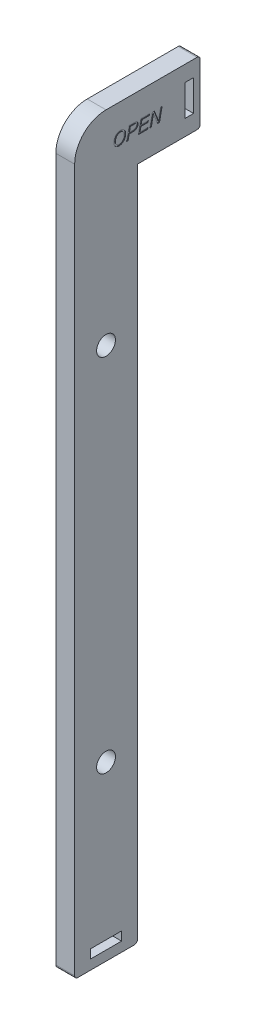
from build123d import *

# Parameters (mm, degrees)
SKETCH_1_R          = 3
SKETCH_1_W          = 2.81
SKETCH_1_H          = 9.9
SKETCH_1_W_2        = 9.9
SKETCH_1_H_2        = 2.81
EXTRUDE_1_DEPTH     = 6
FILLET_1_R          = 1
FILLET_2_R          = 10
CUT_EXTRUDE_1_DEPTH = 0.2


with BuildPart() as part:
    # Эскиз1 → Бобышка-Вытянуть1 (new body)
    with BuildSketch(Plane(origin=(0, 0, 0), x_dir=(0, 0, -1), z_dir=(1, 0, 0))):
        Polygon((0, 0), (0, 215), (20, 215), (20, 235), (-20, 235), (-20, 0), align=None)
        with Locations((-10, 170)):
            Circle(SKETCH_1_R, mode=Mode.SUBTRACT)
        with Locations((-10, 55)):
            Circle(SKETCH_1_R, mode=Mode.SUBTRACT)
        with Locations((16.5, 225)):
            Rectangle(SKETCH_1_W, SKETCH_1_H, mode=Mode.SUBTRACT)
        with Locations((-10, 4.5)):
            Rectangle(SKETCH_1_W_2, SKETCH_1_H_2, mode=Mode.SUBTRACT)
    extrude(amount=EXTRUDE_1_DEPTH)

    # Скругление1
    fillet_1_edges = [part.edges().sort_by_distance(p)[0] for p in [
        (3, 235, -20),
        (3, 215, -20),
        (3, 0, 0),
        (3, 0, 20),
    ]]
    fillet(fillet_1_edges, radius=FILLET_1_R)

    # Скругление2
    fillet_2_edges = [part.edges().sort_by_distance(p)[0] for p in [
        (3, 235, 20),
    ]]
    fillet(fillet_2_edges, radius=FILLET_2_R)

    # Эскиз2 → Вырез-Вытянуть1 (cut)
    with BuildSketch(Plane(origin=(6, 0, 0), x_dir=(0, 0, -1), z_dir=(1, 0, 0))):
        with BuildLine():
            add(Edge.make_bspline(
                [(-7.487179487, 224.677884615), (-7.485326408, 224.764228952), (-7.481701855, 224.933115174), (-7.453533272, 225.180402313), (-7.405449993, 225.414943216), (-7.338993125, 225.637130201), (-7.253996452, 225.846742618), (-7.149347867, 226.04336703), (-7.025073815, 226.227176251), (-6.883090978, 226.396637417), (-6.727847675, 226.549715899), (-6.562769143, 226.683595069), (-6.389954814, 226.797562377), (-6.208419068, 226.890113867), (-6.019193495, 226.962918256), (-5.821389971, 227.014196779), (-5.615570018, 227.045256359), (-5.475535074, 227.049256915), (-5.404647436, 227.051282051)],
                knots=[0, 0, 0, 0, 0.000258993, 0.00050658, 0.000745442, 0.00097638, 0.001201362, 0.001422893, 0.001643355, 0.001865778, 0.002085056, 0.002296419, 0.002502438, 0.00270491, 0.002906548, 0.00310945, 0.003316826, 0.003529421, 0.003529421, 0.003529421, 0.003529421], degree=3))
            add(Edge.make_bspline(
                [(-5.404647436, 227.051282051), (-5.344733658, 227.050103816), (-5.227104213, 227.047790574), (-5.055229995, 227.023499838), (-4.89162471, 226.986403057), (-4.73679064, 226.933371306), (-4.591031255, 226.864500305), (-4.452768198, 226.782053634), (-4.324506847, 226.68224076), (-4.204276819, 226.570025181), (-4.096454743, 226.443984872), (-4.001008783, 226.307571127), (-3.922030267, 226.159685443), (-3.855291131, 226.002622461), (-3.805464676, 225.834464234), (-3.769493026, 225.656434414), (-3.747480766, 225.468233417), (-3.744907385, 225.339269964), (-3.743589744, 225.273237179)],
                knots=[0, 0, 0, 0, 0.000179632, 0.000352674, 0.000519637, 0.000682319, 0.000842547, 0.001002503, 0.001164213, 0.00132917, 0.001495084, 0.001660901, 0.001827617, 0.00199712, 0.002172031, 0.002352748, 0.002541492, 0.00273954, 0.00273954, 0.00273954, 0.00273954], degree=3))
            add(Edge.make_bspline(
                [(-3.743589744, 225.273237179), (-3.744501677, 225.225412884), (-3.746312353, 225.130456103), (-3.756460739, 224.989408881), (-3.775282342, 224.850919386), (-3.800697074, 224.714995056), (-3.833519677, 224.581730978), (-3.874064544, 224.451338896), (-3.920666742, 224.323154229), (-3.958077126, 224.240167875), (-3.976762821, 224.198717949)],
                knots=[0, 0, 0, 0, 0.000143485, 0.000284895, 0.000423943, 0.000562553, 0.000699563, 0.000835412, 0.000972056, 0.001108416, 0.001108416, 0.001108416, 0.001108416], degree=3))
            add(Edge.make_bspline(
                [(-3.976762821, 224.198717949), (-4.006738473, 224.138603197), (-4.065863347, 224.02003106), (-4.171141209, 223.85350135), (-4.287224418, 223.699163445), (-4.414481077, 223.558810008), (-4.549180195, 223.431992287), (-4.689198476, 223.319864604), (-4.833954781, 223.221912027), (-4.935871468, 223.169435313), (-4.986378205, 223.143429487)],
                knots=[0, 0, 0, 0, 0.000201415, 0.000397278, 0.000590067, 0.00078012, 0.000964915, 0.00114449, 0.001317834, 0.001488132, 0.001488132, 0.001488132, 0.001488132], degree=3))
            add(Edge.make_bspline(
                [(-4.986378205, 223.143429487), (-5.019831399, 223.127732662), (-5.086665116, 223.096373109), (-5.190137006, 223.057961737), (-5.294434062, 223.023645555), (-5.400555284, 222.996744895), (-5.507976716, 222.974777914), (-5.617167929, 222.959652913), (-5.727948653, 222.950748644), (-5.802334429, 222.949397466), (-5.83974359, 222.948717949)],
                knots=[0, 0, 0, 0, 0.000110812, 0.000221383, 0.000330851, 0.000440073, 0.000549602, 0.000659635, 0.000770563, 0.000882788, 0.000882788, 0.000882788, 0.000882788], degree=3))
            add(Edge.make_bspline(
                [(-5.83974359, 222.948717949), (-5.878771843, 222.949165688), (-5.955928815, 222.950050847), (-6.070123979, 222.962191112), (-6.181796987, 222.979412045), (-6.290829023, 223.00416944), (-6.396862181, 223.03671596), (-6.500890974, 223.074733064), (-6.601557508, 223.12192274), (-6.700235834, 223.173931071), (-6.793301874, 223.234421204), (-6.882279427, 223.299167712), (-6.964468813, 223.370549532), (-7.041309903, 223.447391309), (-7.112443074, 223.529292162), (-7.176938016, 223.617846126), (-7.236109246, 223.711110268), (-7.288945415, 223.809752436), (-7.334995992, 223.912315871), (-7.375846867, 224.016824833), (-7.410490429, 224.123001263), (-7.438679413, 224.23080954), (-7.460228009, 224.340280293), (-7.475252046, 224.451607017), (-7.485380361, 224.564182982), (-7.486579008, 224.639935397), (-7.487179487, 224.677884615)],
                knots=[0, 0, 0, 0, 0.000117031, 0.000231365, 0.000344129, 0.000455899, 0.000566418, 0.000676707, 0.000787851, 0.000899701, 0.001011059, 0.001120519, 0.001229593, 0.001337246, 0.00144632, 0.001554659, 0.001665587, 0.001777437, 0.001890039, 0.002002681, 0.002113921, 0.002224895, 0.002336782, 0.002448402, 0.002561791, 0.002675619, 0.002675619, 0.002675619, 0.002675619], degree=3))
        make_face()
        with BuildLine():
            add(Edge.make_bspline(
                [(-7.025641026, 224.657051282), (-7.023833006, 224.600566777), (-7.02027956, 224.489553214), (-6.990911579, 224.326622797), (-6.945047988, 224.170495868), (-6.88970571, 224.046970231), (-6.836978531, 223.953540657), (-6.792359627, 223.887226664), (-6.743631054, 223.824582025), (-6.689730233, 223.766224888), (-6.631879455, 223.711308033), (-6.569115496, 223.660773094), (-6.501624927, 223.614158142), (-6.405969853, 223.558293814), (-6.2814255, 223.498672277), (-6.125645497, 223.448300188), (-5.966314499, 223.416303759), (-5.858588772, 223.412278141), (-5.804487179, 223.41025641)],
                knots=[0, 0, 0, 0, 0.000169344, 0.000332825, 0.000495072, 0.000656486, 0.000737586, 0.000816702, 0.000896045, 0.000975441, 0.001054796, 0.001135137, 0.00121693, 0.001300621, 0.00146729, 0.001629968, 0.00179073, 0.001952924, 0.001952924, 0.001952924, 0.001952924], degree=3))
            add(Edge.make_bspline(
                [(-5.804487179, 223.41025641), (-5.752269874, 223.411819916), (-5.648448009, 223.41492858), (-5.495151873, 223.44403348), (-5.34522283, 223.487281359), (-5.200693138, 223.551009776), (-5.061767367, 223.629257666), (-4.929407428, 223.722089627), (-4.805114243, 223.829109848), (-4.688211116, 223.949911703), (-4.580791509, 224.084879712), (-4.485914413, 224.235650064), (-4.402336978, 224.400183537), (-4.333256621, 224.577689171), (-4.276958708, 224.760915329), (-4.235848189, 224.945459008), (-4.209660904, 225.128518395), (-4.206630523, 225.250449713), (-4.205128205, 225.310897436)],
                knots=[0, 0, 0, 0, 0.000156498, 0.00031116, 0.000466578, 0.000623768, 0.000783784, 0.000944283, 0.001107937, 0.001275105, 0.001447924, 0.001624425, 0.001808617, 0.002000712, 0.00219512, 0.002383109, 0.002567483, 0.002748749, 0.002748749, 0.002748749, 0.002748749], degree=3))
            add(Edge.make_bspline(
                [(-4.205128205, 225.310897436), (-4.206190425, 225.358490884), (-4.208261488, 225.451286241), (-4.224846521, 225.586878531), (-4.250579607, 225.715302602), (-4.288494929, 225.836030391), (-4.33687159, 225.949431815), (-4.396151561, 226.055345128), (-4.466491965, 226.153764732), (-4.546289725, 226.243959723), (-4.634374551, 226.324727211), (-4.72830461, 226.395140728), (-4.826541972, 226.456183966), (-4.930593781, 226.505311476), (-5.040108409, 226.542767515), (-5.154336863, 226.570230329), (-5.273574641, 226.586421555), (-5.354651791, 226.588624598), (-5.395833333, 226.58974359)],
                knots=[0, 0, 0, 0, 0.000142738, 0.000278304, 0.000409208, 0.000535162, 0.00065721, 0.000778466, 0.000898533, 0.001019441, 0.001139101, 0.001256409, 0.00137116, 0.001485499, 0.001600798, 0.001717796, 0.001837463, 0.001960988, 0.001960988, 0.001960988, 0.001960988], degree=3))
            add(Edge.make_bspline(
                [(-5.395833333, 226.58974359), (-5.448821476, 226.588314318), (-5.553791237, 226.585482924), (-5.708491898, 226.559464024), (-5.858780571, 226.518689135), (-6.004125819, 226.460702848), (-6.144461193, 226.385965898), (-6.280522091, 226.296205492), (-6.410663121, 226.188173284), (-6.535587224, 226.066145237), (-6.650515278, 225.92999065), (-6.751600173, 225.781443934), (-6.836644582, 225.621542734), (-6.905631204, 225.449989147), (-6.96036598, 225.267713198), (-6.998370547, 225.073958245), (-7.020934822, 224.869125819), (-7.024045325, 224.728957968), (-7.025641026, 224.657051282)],
                knots=[0, 0, 0, 0, 0.000158856, 0.000314695, 0.000469234, 0.00062532, 0.000783032, 0.000945487, 0.001113437, 0.001289655, 0.001468786, 0.001647026, 0.001827692, 0.002011008, 0.002200885, 0.002397787, 0.002602546, 0.002818239, 0.002818239, 0.002818239, 0.002818239], degree=3))
        make_face(mode=Mode.SUBTRACT)
        with BuildLine():
            Line((-3.435897436, 223), (-2.622596154, 227))
            Line((-2.622596154, 227), (-0.948717949, 227))
            add(Edge.make_bspline(
                [(-0.948717949, 227), (-0.913719916, 226.99974272), (-0.845825895, 226.999243613), (-0.747527054, 226.993987008), (-0.655711015, 226.987607678), (-0.570843007, 226.975741694), (-0.492192345, 226.963070404), (-0.420947836, 226.945001144), (-0.356209652, 226.925333077), (-0.279352275, 226.894305116), (-0.190349087, 226.845610856), (-0.095396842, 226.76770115), (-0.0083576, 226.673985476), (0.065334689, 226.562639882), (0.128028665, 226.440491353), (0.173266329, 226.308379118), (0.200195284, 226.16883373), (0.203467983, 226.073302289), (0.205128205, 226.024839744)],
                knots=[0, 0, 0, 0, 0.00010498, 0.000203655, 0.000295285, 0.000380959, 0.000460657, 0.000534118, 0.000601278, 0.000663474, 0.00078255, 0.000903935, 0.001030388, 0.001164844, 0.001303167, 0.001441269, 0.00158239, 0.001727689, 0.001727689, 0.001727689, 0.001727689], degree=3))
            add(Edge.make_bspline(
                [(0.205128205, 226.024839744), (0.20384431, 225.983640497), (0.201246317, 225.900272799), (0.181373025, 225.774799815), (0.147955558, 225.648725338), (0.103440948, 225.523695593), (0.050069027, 225.403380701), (-0.011837418, 225.292507254), (-0.079753991, 225.192073846), (-0.155569771, 225.104496699), (-0.233868304, 225.026892977), (-0.313206775, 224.959431783), (-0.393059998, 224.90158856), (-0.474509519, 224.854387513), (-0.557451661, 224.814552141), (-0.642583724, 224.7813613), (-0.7297217, 224.751674173), (-0.789658015, 224.737750765), (-0.819711538, 224.730769231)],
                knots=[0, 0, 0, 0, 0.000123564, 0.000250034, 0.000380055, 0.000514374, 0.000647801, 0.000774427, 0.000894888, 0.001010828, 0.001121315, 0.001225349, 0.001322968, 0.001416694, 0.001507366, 0.001598726, 0.001690706, 0.001783212, 0.001783212, 0.001783212, 0.001783212], degree=3))
            add(Edge.make_bspline(
                [(-0.819711538, 224.730769231), (-0.885005534, 224.716883), (-1.015493038, 224.689131909), (-1.213608536, 224.661886511), (-1.412603185, 224.644222161), (-1.545635278, 224.642091448), (-1.612179487, 224.641025641)],
                knots=[0, 0, 0, 0, 0.000200202, 0.000400096, 0.000599525, 0.000799123, 0.000799123, 0.000799123, 0.000799123], degree=3))
            Line((-1.612179487, 224.641025641), (-2.631410256, 224.641025641))
            Line((-2.631410256, 224.641025641), (-2.965544872, 223))
            Line((-2.965544872, 223), (-3.435897436, 223))
        make_face()
        with BuildLine():
            Line((-2.537660256, 225.102564103), (-1.603365385, 225.102564103))
            add(Edge.make_bspline(
                [(-1.603365385, 225.102564103), (-1.55955182, 225.102734838), (-1.475090547, 225.103063971), (-1.352766043, 225.10941761), (-1.239345504, 225.116513692), (-1.135137313, 225.128800455), (-1.039787752, 225.143538454), (-0.953827403, 225.163015714), (-0.87605542, 225.183919629), (-0.786242792, 225.218248419), (-0.684591226, 225.268792215), (-0.576491683, 225.344912971), (-0.48125003, 225.433807391), (-0.401896996, 225.53578813), (-0.336746836, 225.645093338), (-0.291049855, 225.760419439), (-0.261001346, 225.878540772), (-0.257941523, 225.958955661), (-0.256410256, 225.999198718)],
                knots=[0, 0, 0, 0, 0.00013142, 0.000253344, 0.000367408, 0.000472266, 0.000568035, 0.000656684, 0.000736592, 0.000809367, 0.000944822, 0.001075978, 0.001204655, 0.001334178, 0.001462396, 0.001585003, 0.001705304, 0.00182582, 0.00182582, 0.00182582, 0.00182582], degree=3))
            add(Edge.make_bspline(
                [(-0.256410256, 225.999198718), (-0.25706713, 226.029210324), (-0.258327, 226.086771978), (-0.275268241, 226.168593041), (-0.29991358, 226.24249921), (-0.337376959, 226.306755182), (-0.382079534, 226.363680198), (-0.437187445, 226.411426283), (-0.500062797, 226.451645278), (-0.55967487, 226.4785512), (-0.614230099, 226.496655167), (-0.664777652, 226.50745519), (-0.723638898, 226.516808121), (-0.791277146, 226.524750616), (-0.867182293, 226.53092886), (-0.951862415, 226.535939724), (-1.045128777, 226.537970252), (-1.110309552, 226.538293378), (-1.144230769, 226.538461538)],
                knots=[0, 0, 0, 0, 8.9872e-05, 0.000172373, 0.000249667, 0.000322517, 0.000394347, 0.000465882, 0.00054012, 0.000617576, 0.000661413, 0.000712343, 0.000772412, 0.000840195, 0.000916586, 0.001000858, 0.001094639, 0.001196405, 0.001196405, 0.001196405, 0.001196405], degree=3))
            Line((-1.144230769, 226.538461538), (-2.245192308, 226.538461538))
            Line((-2.245192308, 226.538461538), (-2.537660256, 225.102564103))
        make_face(mode=Mode.SUBTRACT)
        Polygon((0.256410256, 223), (1.076923077, 227), (3.897435897, 227), (3.823717949, 226.538461538), (1.453525641, 226.538461538), (1.201121795, 225.307692308), (3.487179487, 225.307692308), (3.384615385, 224.846153846), (1.107371795, 224.846153846), (0.821314103, 223.461538462), (3.346955128, 223.461538462), (3.253205128, 223), align=None)
        with BuildLine():
            Line((3.948717949, 223), (4.769230769, 227))
            Line((4.769230769, 227), (5.360576923, 227))
            Line((5.360576923, 227), (5.997596154, 225.480769231))
            add(Edge.make_bspline(
                [(5.997596154, 225.480769231), (6.021094054, 225.423875725), (6.067086033, 225.312519179), (6.134637232, 225.149264978), (6.197747137, 224.992562191), (6.258441845, 224.843164989), (6.31286572, 224.699720908), (6.365673603, 224.564148116), (6.413543044, 224.43495684), (6.444208908, 224.350972876), (6.459134615, 224.310096154)],
                knots=[0, 0, 0, 0, 0.000184666, 0.000361442, 0.000530028, 0.00069147, 0.000845187, 0.000990274, 0.001127948, 0.001258498, 0.001258498, 0.001258498, 0.001258498], degree=3))
            add(Edge.make_bspline(
                [(6.459134615, 224.310096154), (6.467513743, 224.286090968), (6.484967659, 224.236087612), (6.510126485, 224.157577107), (6.53763537, 224.073613839), (6.565693238, 223.983599576), (6.594522093, 223.887434996), (6.624044949, 223.78509742), (6.654448285, 223.676568145), (6.675216752, 223.60229785), (6.685897436, 223.564102564)],
                knots=[0, 0, 0, 0, 7.6273e-05, 0.000158879, 0.000247315, 0.000341338, 0.000441726, 0.000548489, 0.000660866, 0.000779848, 0.000779848, 0.000779848, 0.000779848], degree=3))
            add(Edge.make_bspline(
                [(6.685897436, 223.564102564), (6.722171402, 223.741463431), (6.794782526, 224.096494143), (6.868004558, 224.451399365), (6.904647436, 224.62900641)],
                knots=[0, 0, 0, 0, 0.000543097, 0.001087139, 0.001087139, 0.001087139, 0.001087139], degree=3))
            Line((6.904647436, 224.62900641), (7.391826923, 227))
            Line((7.391826923, 227), (7.860576923, 227))
            Line((7.860576923, 227), (7.037660256, 223))
            Line((7.037660256, 223), (6.423076923, 223))
            Line((6.423076923, 223), (5.540064103, 225.287660256))
            add(Edge.make_bspline(
                [(5.540064103, 225.287660256), (5.50124575, 225.3875188), (5.425728307, 225.581784173), (5.316958374, 225.865989981), (5.213686364, 226.133818396), (5.146898341, 226.307156822), (5.114583333, 226.391025641)],
                knots=[0, 0, 0, 0, 0.000321414, 0.000625281, 0.000912924, 0.001182561, 0.001182561, 0.001182561, 0.001182561], degree=3))
            add(Edge.make_bspline(
                [(5.114583333, 226.391025641), (5.100231022, 226.320231196), (5.070162742, 226.1719159), (5.021629361, 225.940014616), (4.970832253, 225.687935762), (4.934652548, 225.513603206), (4.915865385, 225.423076923)],
                knots=[0, 0, 0, 0, 0.000216703, 0.000453997, 0.000710772, 0.000988137, 0.000988137, 0.000988137, 0.000988137], degree=3))
            Line((4.915865385, 225.423076923), (4.419070513, 223))
            Line((4.419070513, 223), (3.948717949, 223))
        make_face()
    extrude(amount=-CUT_EXTRUDE_1_DEPTH, mode=Mode.SUBTRACT)


solid = part.part
